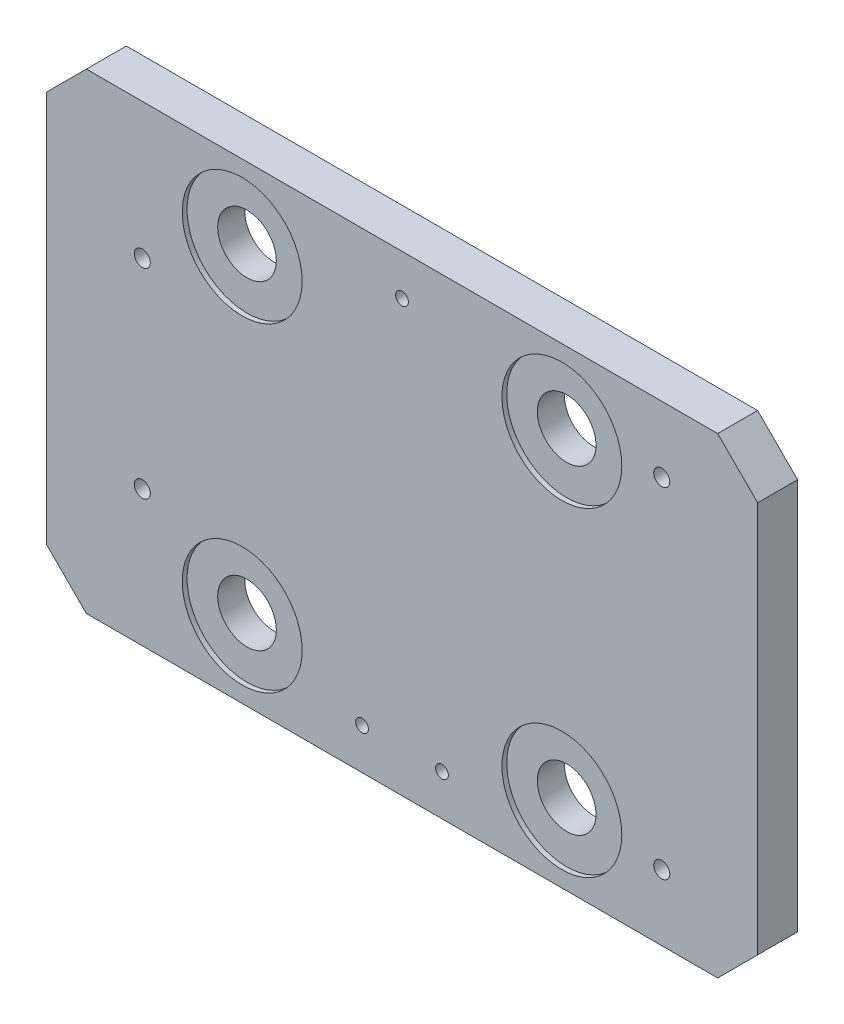
from build123d import *

# Parameters (mm, degrees)
SKETCH3_W                                        = 226.06
SKETCH3_H                                        = 149.86
EXTRUDE2_DEPTH                                   = 12.7
F_1_4_20_TAPPED_HOLE1_D                          = 5.1054
CBORE_FOR_5_8_SOCKET_HEAD_CAP_SCREW1_D           = 18.6436
CBORE_FOR_5_8_SOCKET_HEAD_CAP_SCREW1_CBORE_D     = 38.1
CBORE_FOR_5_8_SOCKET_HEAD_CAP_SCREW1_CBORE_DEPTH = 2.54
F_10_32_TAPPED_HOLE1_D                           = 4.0386
CHAMFER1_SIZE                                    = 12.7
SKETCH20_R                                       = 19.05
CUT_EXTRUDE5_DEPTH                               = 1.524


with BuildPart() as part:
    # Sketch3 → Extrude2 (new body)
    with BuildSketch(Plane.XY):
        with Locations((113.03, -74.93)):
            Rectangle(SKETCH3_W, SKETCH3_H)
    extrude(amount=EXTRUDE2_DEPTH)

    # 1/4-20 Tapped Hole1 (through all)
    with Locations(Plane(origin=(0, 0, 0), x_dir=(-1, 0, 0), z_dir=(0, 0, -1))):
        with Locations((-195.58, -20.955), (-195.58, -128.905), (-30.48, -43.18), (-30.48, -106.68)):
            Hole(F_1_4_20_TAPPED_HOLE1_D / 2)

    # CBORE for 5/8 Socket Head Cap Screw1 (through all)
    with Locations(Plane(origin=(163.83, -24.13, 0), x_dir=(-1, 0, 0), z_dir=(0, 0, -1))):
        with Locations((0, 0), (101.6, 0), (101.6, -101.6), (0, -101.6)):
            CounterBoreHole(CBORE_FOR_5_8_SOCKET_HEAD_CAP_SCREW1_D / 2, CBORE_FOR_5_8_SOCKET_HEAD_CAP_SCREW1_CBORE_D / 2, CBORE_FOR_5_8_SOCKET_HEAD_CAP_SCREW1_CBORE_DEPTH)

    # #10-32 Tapped Hole1 (through all)
    with Locations(Plane(origin=(0, 0, 0), x_dir=(-1, 0, 0), z_dir=(0, 0, -1))):
        with Locations((-113.03, -13.0048), (-125.73, -136.8552), (-100.33, -136.8552)):
            Hole(F_10_32_TAPPED_HOLE1_D / 2)

    # Chamfer1
    chamfer1_edges = [part.edges().sort_by_distance(p)[0] for p in [
        (0, 0, 6.35),
        (226.06, 0, 6.35),
        (226.06, -149.86, 6.35),
        (0, -149.86, 6.35),
    ]]
    chamfer(chamfer1_edges, length=CHAMFER1_SIZE)

    # Sketch20 → Cut-Extrude5 (cut)
    with BuildSketch(Plane.XY.offset(12.7)):
        with Locations(Location((163.83, -125.73, 0), (0, 0, 180))):  # turned: the seam where the file's is
            Circle(SKETCH20_R)
        with Locations(Location((62.23, -125.73, 0), (0, 0, 180))):  # turned: the seam where the file's is
            Circle(SKETCH20_R)
        with Locations(Location((163.83, -24.13, 0), (0, 0, 180))):  # turned: the seam where the file's is
            Circle(SKETCH20_R)
        with Locations(Location((62.23, -24.13, 0), (0, 0, 180))):  # turned: the seam where the file's is
            Circle(SKETCH20_R)
    extrude(amount=-CUT_EXTRUDE5_DEPTH, mode=Mode.SUBTRACT)


solid = part.part
